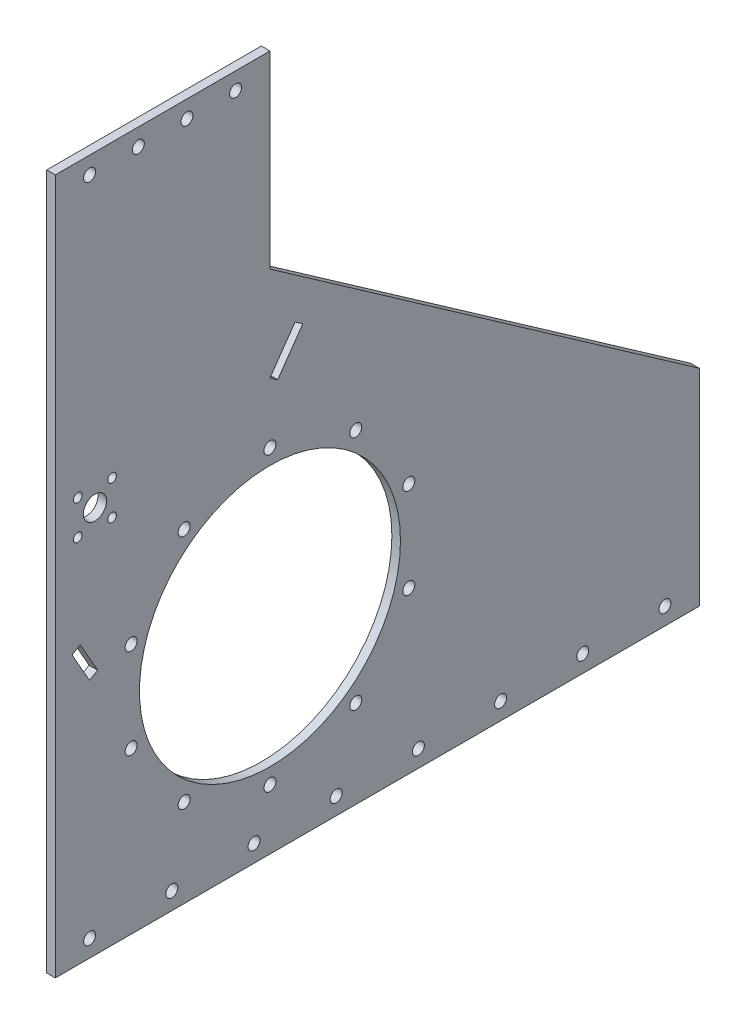
from build123d import *

# Parameters (mm, degrees)
IZIM1_R                     = 152
IZIM1_R_2                   = 7
IZIM1_R_3                   = 13.5
IZIM1_R_4                   = 5.1
Y_KSEKLIK_EKSTR_ZYON1_DEPTH = 10


with BuildPart() as part:
    # Çizim1 → Yükseklik-Ekstrüzyon1 (new body)
    with BuildSketch(Plane(origin=(0, 0, 0), x_dir=(0, 0, -1), z_dir=(1, 0, 0))):
        Polygon((-250, 350), (-250, 570), (0, 570), (0, 350), (500, 0), (500, -200), (500, -240), (-250, -240), (-250, -200), align=None)
        Circle(IZIM1_R, mode=Mode.SUBTRACT)
        with Locations((0, 170)):
            Circle(IZIM1_R_2, mode=Mode.SUBTRACT)
        with Locations((99.92349289, 137.532889044)):
            Circle(IZIM1_R_2, mode=Mode.SUBTRACT)
        with Locations((161.67960777, 52.532889044)):
            Circle(IZIM1_R_2, mode=Mode.SUBTRACT)
        with Locations((161.67960777, -52.532889044)):
            Circle(IZIM1_R_2, mode=Mode.SUBTRACT)
        with Locations((99.92349289, -137.532889044)):
            Circle(IZIM1_R_2, mode=Mode.SUBTRACT)
        with Locations((0, -170)):
            Circle(IZIM1_R_2, mode=Mode.SUBTRACT)
        with Locations((-99.92349289, -137.532889044)):
            Circle(IZIM1_R_2, mode=Mode.SUBTRACT)
        with Locations((-161.67960777, -52.532889044)):
            Circle(IZIM1_R_2, mode=Mode.SUBTRACT)
        with Locations((-161.67960777, 52.532889044)):
            Circle(IZIM1_R_2, mode=Mode.SUBTRACT)
        with Locations((-99.92349289, 137.532889044)):
            Circle(IZIM1_R_2, mode=Mode.SUBTRACT)
        with Locations((-203.812062632, 211.374016696)):
            Circle(IZIM1_R_3, mode=Mode.SUBTRACT)
        with Locations((-183.812062632, 231.374016696)):
            Circle(IZIM1_R_4, mode=Mode.SUBTRACT)
        with Locations((-223.812062632, 231.374016696)):
            Circle(IZIM1_R_4, mode=Mode.SUBTRACT)
        with Locations((-183.812062632, 191.374016696)):
            Circle(IZIM1_R_4, mode=Mode.SUBTRACT)
        with Locations((-223.812062632, 191.374016696)):
            Circle(IZIM1_R_4, mode=Mode.SUBTRACT)
        with Locations((-210, 550)):
            Circle(IZIM1_R_2, mode=Mode.SUBTRACT)
        with Locations((-153.333333333, 550)):
            Circle(IZIM1_R_2, mode=Mode.SUBTRACT)
        with Locations((-96.666666667, 550)):
            Circle(IZIM1_R_2, mode=Mode.SUBTRACT)
        with Locations((-40, 550)):
            Circle(IZIM1_R_2, mode=Mode.SUBTRACT)
        with Locations((-210, -220)):
            Circle(IZIM1_R_2, mode=Mode.SUBTRACT)
        with Locations((-114.285714286, -220)):
            Circle(IZIM1_R_2, mode=Mode.SUBTRACT)
        with Locations((-18.571428571, -220)):
            Circle(IZIM1_R_2, mode=Mode.SUBTRACT)
        with Locations((77.142857143, -220)):
            Circle(IZIM1_R_2, mode=Mode.SUBTRACT)
        with Locations((172.857142857, -220)):
            Circle(IZIM1_R_2, mode=Mode.SUBTRACT)
        with Locations((268.571428571, -220)):
            Circle(IZIM1_R_2, mode=Mode.SUBTRACT)
        with Locations((364.285714286, -220)):
            Circle(IZIM1_R_2, mode=Mode.SUBTRACT)
        with Locations((460, -220)):
            Circle(IZIM1_R_2, mode=Mode.SUBTRACT)
        Polygon((29.246579563, 281.988117893), (0, 240.207289947), (9.011551126, 233.899204159), (38.258130688, 275.680032105), align=None, mode=Mode.SUBTRACT)
        Polygon((-200.681608906, 45.789510008), (-220.902149255, 81.456437938), (-230.471325041, 76.031414918), (-210.250784693, 40.364486987), align=None, mode=Mode.SUBTRACT)
    extrude(amount=Y_KSEKLIK_EKSTR_ZYON1_DEPTH)


solid = part.part
